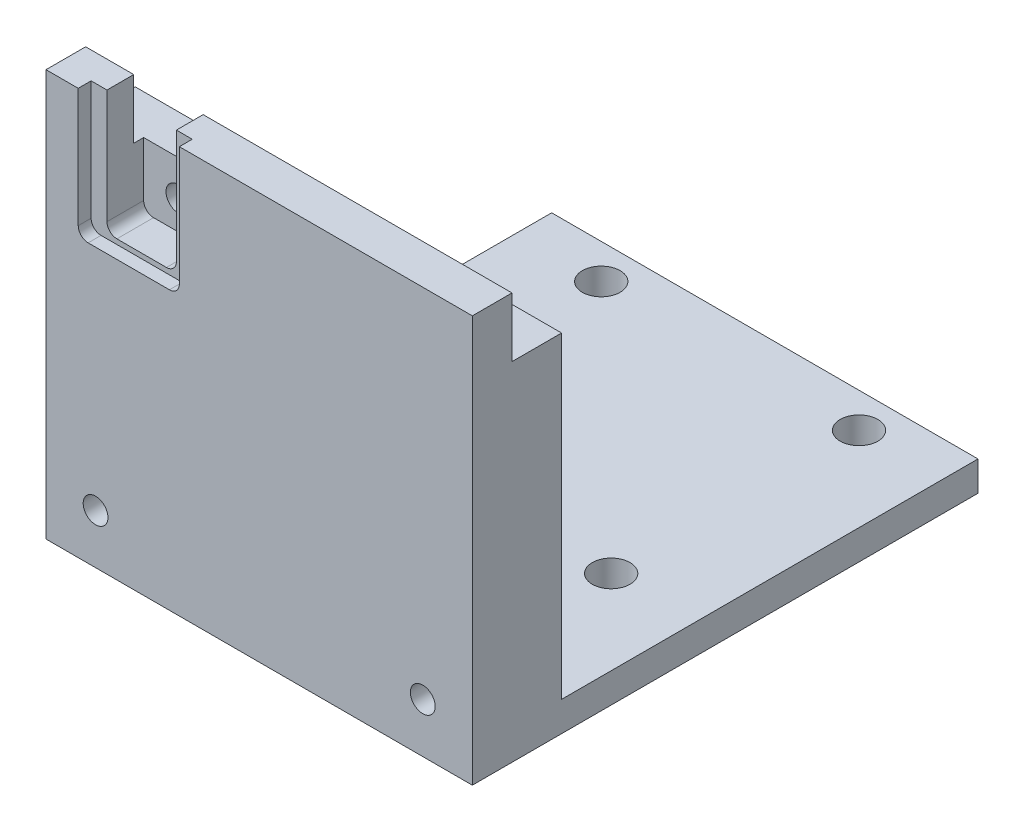
from build123d import *

# Parameters (mm, degrees)
SKETCH_1_W           = 43
SKETCH_1_H           = 38
EXTRUDE_1_DEPTH      = 9
SKETCH_2_W           = 43
SKETCH_2_H           = 3
EXTRUDE_3_DEPTH      = 51
SKETCH_3_R           = 1.900733336
CUT_EXTRUDE_1_DEPTH  = 42
SKETCH_4_W           = 5
SKETCH_4_H           = 6
CUT_EXTRUDE_2_DEPTH  = 44
SKETCH_8_R           = 1.25
CUT_EXTRUDE_6_DEPTH  = 9
SKETCH_7_R           = 1.2
CUT_EXTRUDE_7_DEPTH  = 15
SKETCH_9_W           = 10.2
SKETCH_9_H           = 13
CUT_EXTRUDE_8_DEPTH  = 1.3
SKETCH_11_W          = 7
SKETCH_11_H          = 12.5
CUT_EXTRUDE_13_DEPTH = 3.7
SKETCH_10_R          = 1.25
CUT_EXTRUDE_14_DEPTH = 8
FILLET_1_R           = 1
FILLET_2_R           = 1


with BuildPart() as part:
    # Эскиз1 → Бобышка-Вытянуть1 (new body)
    with BuildSketch(Plane.XY):
        Rectangle(SKETCH_1_W, SKETCH_1_H)
    extrude(amount=EXTRUDE_1_DEPTH)

    # Эскиз2 → Бобышка-Вытянуть3 (add)
    with BuildSketch(Plane.XY.offset(9)):
        with Locations((0, -20.5)):
            Rectangle(SKETCH_2_W, SKETCH_2_H)
    extrude(amount=-EXTRUDE_3_DEPTH)

    # Эскиз3 → Вырез-Вытянуть1 (cut, through all)
    with BuildSketch(Plane.XZ.offset(22)):
        with Locations(Location((-13, -38.5, 0), (0, 0, 270))):  # turned: the seam where the file's is
            Circle(SKETCH_3_R)
        with Locations(Location((13, -38.5, 0), (0, 0, 270))):  # turned: the seam where the file's is
            Circle(SKETCH_3_R)
        with Locations(Location((13, -13.5, 0), (0, 0, 270))):  # turned: the seam where the file's is
            Circle(SKETCH_3_R)
        with Locations(Location((-13, -13.5, 0), (0, 0, 270))):  # turned: the seam where the file's is
            Circle(SKETCH_3_R)
    extrude(amount=-CUT_EXTRUDE_1_DEPTH, mode=Mode.SUBTRACT)

    # Эскиз4 → Вырез-Вытянуть2 (cut, through all)
    with BuildSketch(Plane.ZY.offset(21.5)):
        with Locations((2.5, 16)):
            Rectangle(SKETCH_4_W, SKETCH_4_H)
    extrude(amount=-CUT_EXTRUDE_2_DEPTH, mode=Mode.SUBTRACT)

    # Эскиз8 → Вырез-Вытянуть6 (cut)
    with BuildSketch(Plane.XY.offset(9)):
        with Locations((16.5, -17)):
            Circle(SKETCH_8_R)
        with Locations((-16.5, -17)):
            Circle(SKETCH_8_R)
    extrude(amount=-CUT_EXTRUDE_6_DEPTH, mode=Mode.SUBTRACT)

    # Эскиз7 → Вырез-Вытянуть7 (cut)
    with BuildSketch(Plane(origin=(0, 13, 0), x_dir=(1, 0, 0), z_dir=(0, 1, 0))):
        with Locations(Location((16.5, -2.5, 0), (0, 0, 270))):  # turned: the seam where the file's is
            Circle(SKETCH_7_R)
        with Locations(Location((6.5, -2.5, 0), (0, 0, 270))):  # turned: the seam where the file's is
            Circle(SKETCH_7_R)
        with Locations(Location((-3.5, -2.5, 0), (0, 0, 270))):  # turned: the seam where the file's is
            Circle(SKETCH_7_R)
    extrude(amount=-CUT_EXTRUDE_7_DEPTH, mode=Mode.SUBTRACT)

    # Эскиз9 → Вырез-Вытянуть8 (cut)
    with BuildSketch(Plane.XY.offset(9)):
        with Locations((-13.15, 12.5)):
            Rectangle(SKETCH_9_W, SKETCH_9_H)
    extrude(amount=-CUT_EXTRUDE_8_DEPTH, mode=Mode.SUBTRACT)

    # Эскиз11 → Вырез-Вытянуть13 (cut)
    with BuildSketch(Plane.XY.offset(7.7)):
        with Locations((-13.15, 12.75)):
            Rectangle(SKETCH_11_W, SKETCH_11_H)
    extrude(amount=-CUT_EXTRUDE_13_DEPTH, mode=Mode.SUBTRACT)

    # Эскиз10 → Вырез-Вытянуть14 (cut)
    with BuildSketch(Plane.XY.offset(7.7)):
        with Locations((-13.149995044, 9.4)):
            Circle(SKETCH_10_R)
    extrude(amount=-CUT_EXTRUDE_14_DEPTH, mode=Mode.SUBTRACT)

    # Скругление1
    fillet_1_edges = [part.edges().sort_by_distance(p)[0] for p in [
        (-16.65, 6.5, 5.85),
        (-9.65, 6.5, 5.85),
    ]]
    fillet(fillet_1_edges, radius=FILLET_1_R)

    # Скругление2
    fillet_2_edges = [part.edges().sort_by_distance(p)[0] for p in [
        (-8.05, 6, 8.35),
        (-18.25, 6, 8.35),
    ]]
    fillet(fillet_2_edges, radius=FILLET_2_R)


solid = part.part
